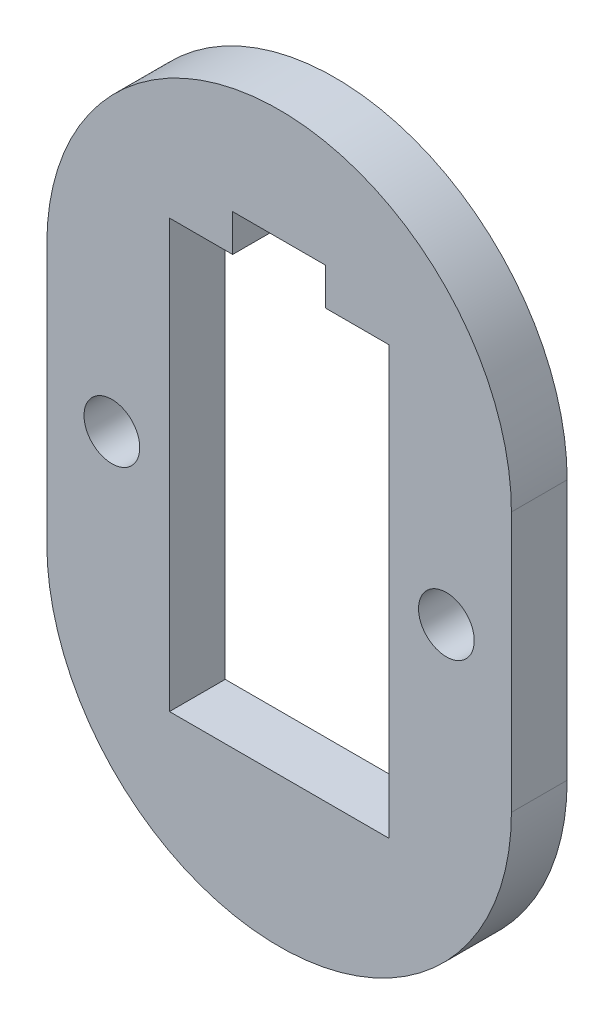
from build123d import *

# Parameters (mm, degrees)
MODEL_R             = 1.500000002
BOSS_EXTRUDE1_DEPTH = 3


with BuildPart() as part:
    # Model → Boss-Extrude1 (new body)
    with BuildSketch(Plane.XY):
        with BuildLine():
            Line((64.5, 48.999991226), (64.5, 34.999991225))
            ThreePointArc((64.5, 34.999991225), (52, 22.499991225), (39.5, 34.999991225))
            Line((39.5, 34.999991225), (39.5, 49.000091226))
            ThreePointArc((39.5, 49.000091226), (52.00005, 61.500041226), (64.5, 48.999991226))
        make_face()
        with Locations((42.999999998, 41.999991225)):
            Circle(MODEL_R, mode=Mode.SUBTRACT)
        with Locations((60.999999998, 41.999991225)):
            Circle(MODEL_R, mode=Mode.SUBTRACT)
        Polygon((54.5, 55.500091226), (54.5, 53.499991226), (57.9, 53.499991226), (57.9, 30.499991226), (46.1, 30.499991226), (46.1, 53.499991226), (49.5, 53.499991226), (49.5, 55.500091226), align=None, mode=Mode.SUBTRACT)
    extrude(amount=BOSS_EXTRUDE1_DEPTH)


solid = part.part
